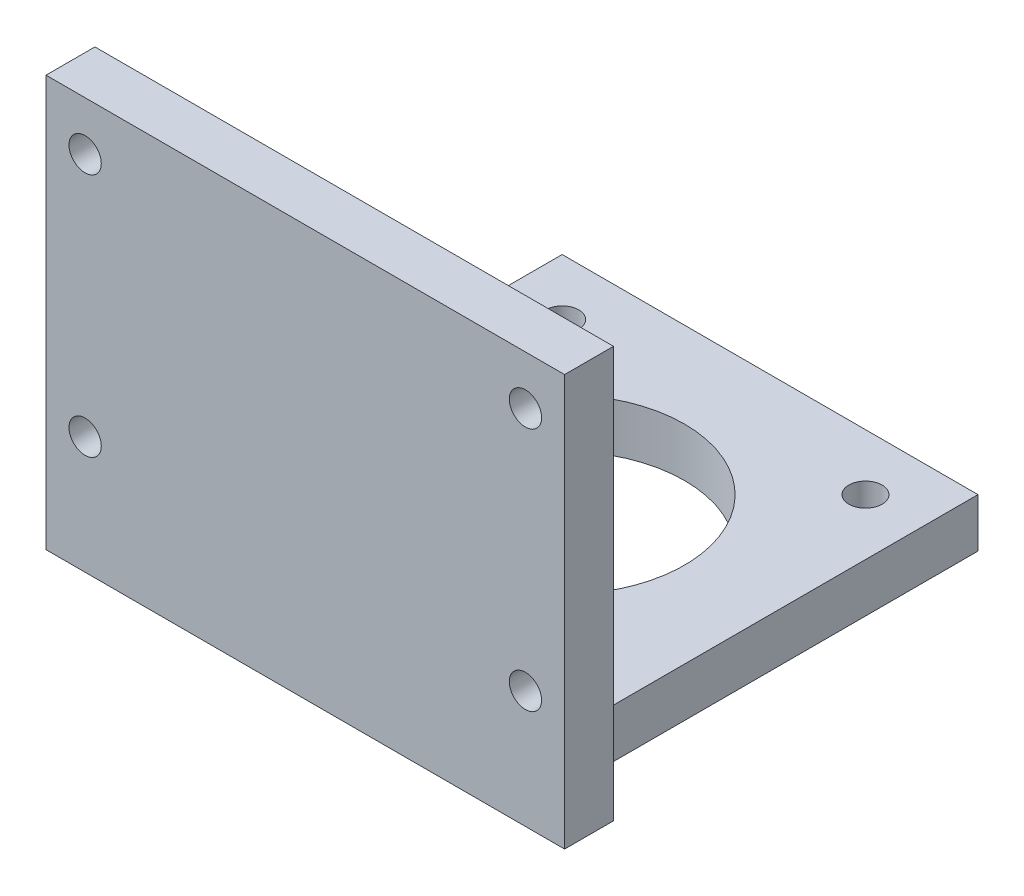
from build123d import *

# Parameters (mm, degrees)
SKETCH1_W           = 42.5
SKETCH1_H           = 42.5
SKETCH1_R           = 1.7
SKETCH1_R_2         = 12.5
BOSS_EXTRUDE1_DEPTH = 5
SKETCH3_W           = 53
SKETCH3_H           = 5
BOSS_EXTRUDE3_DEPTH = 42
SKETCH4_R           = 1.65
CUT_EXTRUDE1_DEPTH  = 42


with BuildPart() as part:
    # Sketch1 → Boss-Extrude1 (new body)
    with BuildSketch(Plane(origin=(0, 0, 0), x_dir=(1, 0, 0), z_dir=(0, 1, 0))):
        Rectangle(SKETCH1_W, SKETCH1_H)
        with Locations((-15.5, 15.5)):
            Circle(SKETCH1_R, mode=Mode.SUBTRACT)
        with Locations((15.5, 15.5)):
            Circle(SKETCH1_R, mode=Mode.SUBTRACT)
        with Locations((-15.5, -15.5)):
            Circle(SKETCH1_R, mode=Mode.SUBTRACT)
        with Locations((15.5, -15.5)):
            Circle(SKETCH1_R, mode=Mode.SUBTRACT)
        Circle(SKETCH1_R_2, mode=Mode.SUBTRACT)
    extrude(amount=BOSS_EXTRUDE1_DEPTH)

    # Sketch3 → Boss-Extrude3 (add)
    with BuildSketch(Plane(origin=(0, 0, 0), x_dir=(1, 0, 0), z_dir=(0, 1, 0))):
        with Locations((0, -23.75)):
            Rectangle(SKETCH3_W, SKETCH3_H)
    extrude(amount=BOSS_EXTRUDE3_DEPTH)

    # Sketch4 → Cut-Extrude1 (cut)
    with BuildSketch(Plane.XY.offset(26.25)):
        with Locations((22.5, 37)):
            Circle(SKETCH4_R)
        with Locations((22.5, 12)):
            Circle(SKETCH4_R)
        with Locations((-22.5, 37)):
            Circle(SKETCH4_R)
        with Locations((-22.5, 12)):
            Circle(SKETCH4_R)
    extrude(amount=-CUT_EXTRUDE1_DEPTH, mode=Mode.SUBTRACT)


solid = part.part
